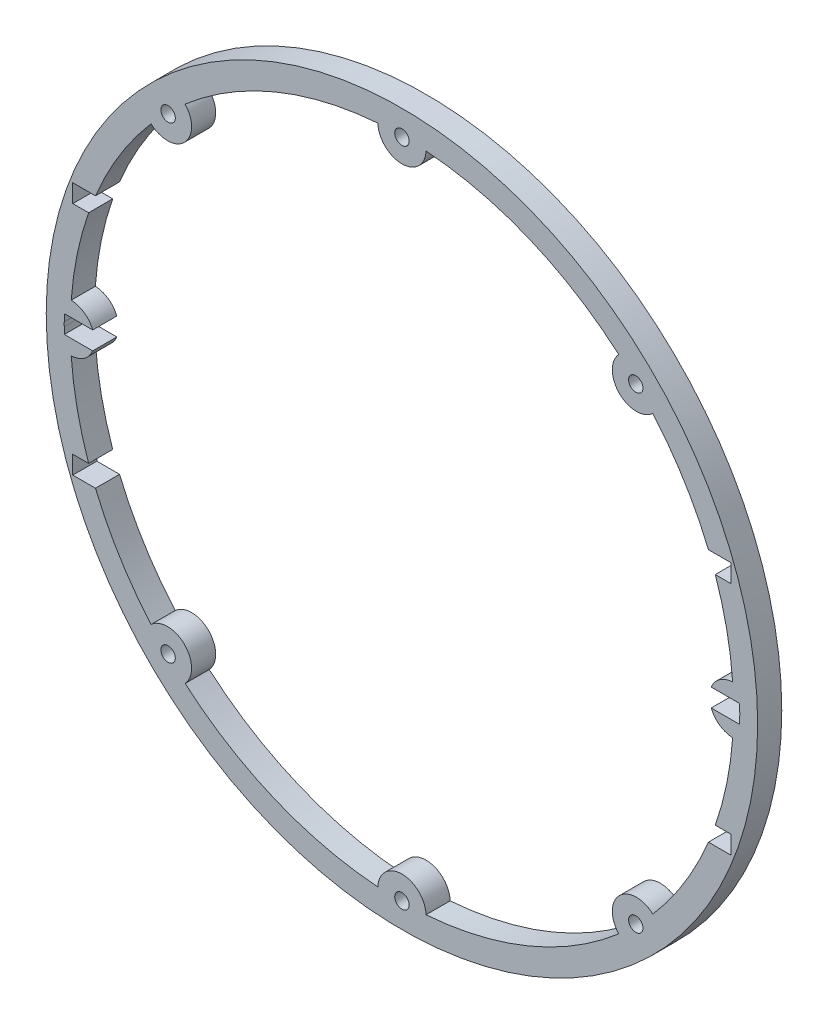
from build123d import *

# Parameters (mm, degrees)
SKETCH1_R                 = 93.6625
SKETCH1_R_2               = 87.3125
BOSS_EXTRUDE1_DEPTH       = 6.35
BOSS_EXTRUDE2_DEPTH       = 6.35
SKETCH4_W                 = 173.355
SKETCH4_H                 = 4.7625
SKETCH4_W_2               = 177.8
CUT_EXTRUDE2_DEPTH        = 6.35
F_6_CLEARANCE_HOLE1_D     = 3.7973
F_6_CLEARANCE_HOLE1_DEPTH = 25.4
F_6_CLEARANCE_HOLE1_TIP   = 1.140824014


with BuildPart() as part:
    # Sketch1 → Boss-Extrude1 (new body)
    with BuildSketch(Plane.XY):
        Circle(SKETCH1_R)
        Circle(SKETCH1_R_2, mode=Mode.SUBTRACT)
    extrude(amount=BOSS_EXTRUDE1_DEPTH)

    # Sketch3 → Boss-Extrude2 (add, through all)
    with BuildSketch(Plane.XY.offset(6.35)):
        with BuildLine():
            ThreePointArc((-66.063141847, 57.08882505), (-57.249132772, 57.249132772), (-57.08882505, 66.063141847))
            ThreePointArc((-57.08882505, 66.063141847), (-61.739260832, 61.739260832), (-66.063141847, 57.08882505))
        make_face()
        with BuildLine():
            ThreePointArc((6.345800264, 87.081590909), (0, 87.3125), (-6.345800264, 87.081590909))
            ThreePointArc((-6.345800264, 87.081590909), (0, 80.9625), (6.345800264, 87.081590909))
        make_face()
        with BuildLine():
            ThreePointArc((66.063141847, 57.08882505), (61.739260832, 61.739260832), (57.08882505, 66.063141847))
            ThreePointArc((57.08882505, 66.063141847), (57.249132772, 57.249132772), (66.063141847, 57.08882505))
        make_face()
        with BuildLine():
            ThreePointArc((87.3125, 0), (87.254753631, 3.175), (87.081590909, 6.345800264))
            ThreePointArc((87.081590909, 6.345800264), (80.9625, 0), (87.081590909, -6.345800264))
            ThreePointArc((87.081590909, -6.345800264), (87.254753631, -3.175), (87.3125, 0))
        make_face()
        with BuildLine():
            ThreePointArc((57.08882505, -66.063141847), (61.739260832, -61.739260832), (66.063141847, -57.08882505))
            ThreePointArc((66.063141847, -57.08882505), (57.249132772, -57.249132772), (57.08882505, -66.063141847))
        make_face()
        with BuildLine():
            ThreePointArc((6.345800264, -87.081590909), (0, -80.9625), (-6.345800264, -87.081590909))
            ThreePointArc((-6.345800264, -87.081590909), (0, -87.3125), (6.345800264, -87.081590909))
        make_face()
        with BuildLine():
            ThreePointArc((-57.08882505, -66.063141847), (-57.249132772, -57.249132772), (-66.063141847, -57.08882505))
            ThreePointArc((-66.063141847, -57.08882505), (-61.739260832, -61.739260832), (-57.08882505, -66.063141847))
        make_face()
        with BuildLine():
            ThreePointArc((-87.081590909, -6.345800264), (-80.9625, 0), (-87.081590909, 6.345800264))
            ThreePointArc((-87.081590909, 6.345800264), (-87.3125, 0), (-87.081590909, -6.345800264))
        make_face()
    extrude(amount=-BOSS_EXTRUDE2_DEPTH)

    # Sketch4 → Cut-Extrude2 (cut)
    with BuildSketch(Plane.XY.offset(6.35)):
        with Locations((0, 30.95625)):
            Rectangle(SKETCH4_W, SKETCH4_H)
        Rectangle(SKETCH4_W_2, SKETCH4_H)
        with Locations((0, -30.95625)):
            Rectangle(SKETCH4_W, SKETCH4_H)
    extrude(amount=-CUT_EXTRUDE2_DEPTH, mode=Mode.SUBTRACT)

    # #6 Clearance Hole1
    with Locations(Plane.XY.offset(6.35)):
        with Locations((-87.081590909, 0), (-61.575983448, 61.575983448), (0, 87.081590909), (61.575983448, 61.575983448), (87.081590909, 0), (61.575983448, -61.575983448), (0, -87.081590909), (-61.575983448, -61.575983448)):
            Hole(F_6_CLEARANCE_HOLE1_D / 2, depth=F_6_CLEARANCE_HOLE1_DEPTH)
            with Locations((0, 0, -(F_6_CLEARANCE_HOLE1_DEPTH + F_6_CLEARANCE_HOLE1_TIP / 2))):  # 118° drill point
                Cone(0, F_6_CLEARANCE_HOLE1_D / 2, F_6_CLEARANCE_HOLE1_TIP, mode=Mode.SUBTRACT)


solid = part.part
